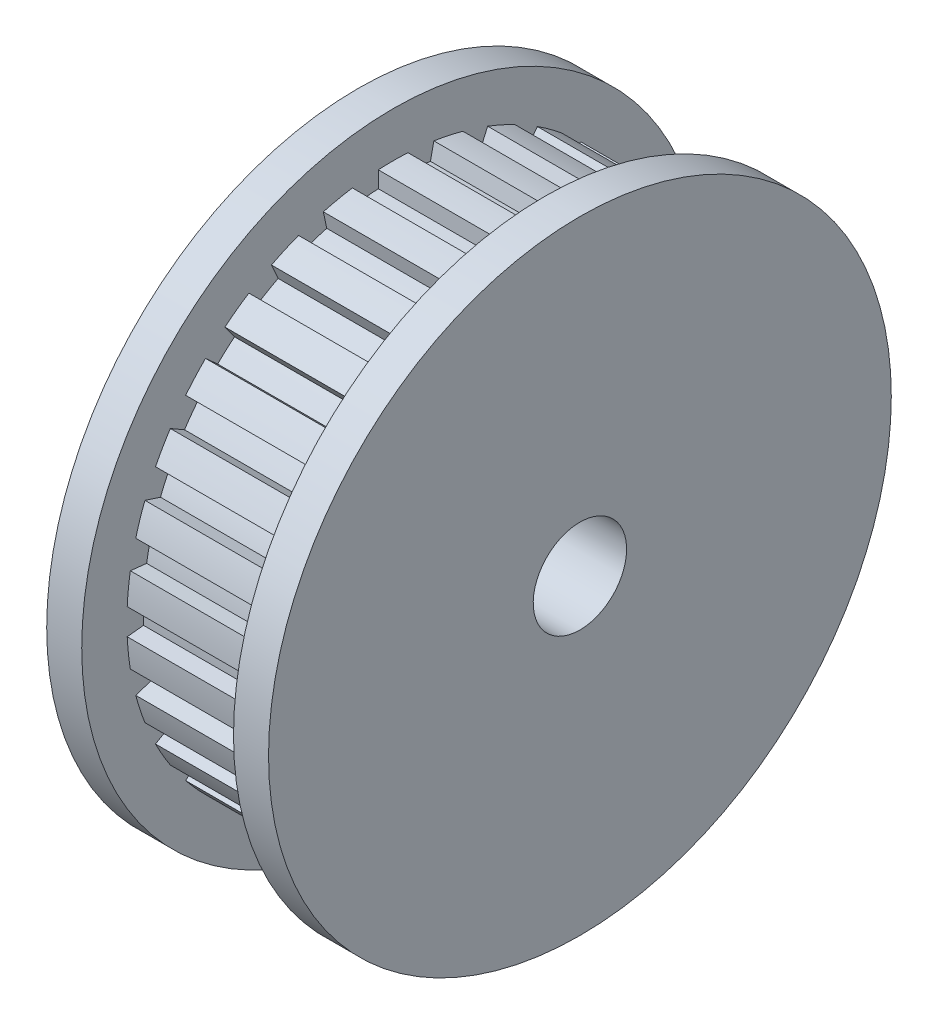
from build123d import *

# Parameters (mm, degrees)
SKETCH2_R           = 13.335
SKETCH2_R_2         = 1.999999624
BOSS_EXTRUDE1_DEPTH = 9.5
SKETCH4_W           = 6.5
SKETCH4_H           = 3.81
BOSS_EXTRUDE2_DEPTH = 6.5


with BuildPart() as part:
    # Sketch2 → Boss-Extrude1 (new body)
    with BuildSketch(Plane.ZY.offset(64.634662924)):
        with Locations((18.152779015, -99.41404144)):
            Circle(SKETCH2_R)
        with Locations((18.152779015, -99.41404144)):
            Circle(SKETCH2_R_2, mode=Mode.SUBTRACT)
    extrude(amount=-BOSS_EXTRUDE1_DEPTH)

    # Sketch4 → Cut-Revolve1 (revolve, cut)
    with BuildSketch(Plane(origin=(0, 0, 18.152779015), x_dir=(-1, 0, 0), z_dir=(0, 0, -1))):
        with Locations((59.884662924, -86.80904144)):
            Rectangle(SKETCH4_W, SKETCH4_H)
    revolve(axis=Axis((-52.493283678, -99.41404144, 18.152779015), (-1, 0, 0)), mode=Mode.SUBTRACT)

    # Sketch5 → Boss-Extrude2 (add)
    with BuildSketch(Plane(origin=(-63.134662924, 0, 0), x_dir=(0, 0, -1), z_dir=(1, 0, 0))):
        with BuildLine():
            Line((-18.787779015, -88.031243858), (-18.787779015, -88.732900349))
            ThreePointArc((-18.787779015, -88.732900349), (-18.152779015, -88.71404144), (-17.517779015, -88.732900349))
            Line((-17.517779015, -88.732900349), (-17.517779015, -88.031243858))
            ThreePointArc((-17.517779015, -88.031243858), (-18.152779015, -88.013545583), (-18.787779015, -88.031243858))
        make_face()
        with BuildLine():
            Line((-16.40728605, -88.147961372), (-16.553168638, -88.834284985))
            ThreePointArc((-16.553168638, -88.834284985), (-15.928123924, -88.947862112), (-15.310921185, -89.098332832))
            Line((-15.310921185, -89.098332832), (-15.165038597, -88.41200922))
            ThreePointArc((-15.165038597, -88.41200922), (-15.782482646, -88.26267377), (-16.40728605, -88.147961372))
        make_face()
        with BuildLine():
            Line((-14.103079504, -88.757060646), (-14.388468909, -89.398055745))
            ThreePointArc((-14.388468909, -89.398055745), (-13.800696934, -89.639105043), (-13.228266178, -89.914611282))
            Line((-13.228266178, -89.914611282), (-12.942876773, -89.273616182))
            ThreePointArc((-12.942876773, -89.273616182), (-13.515779601, -88.999170235), (-14.103079504, -88.757060646))
        make_face()
        with BuildLine():
            Line((-11.975864259, -89.831921118), (-12.388287596, -90.399573143))
            ThreePointArc((-12.388287596, -90.399573143), (-11.863476816, -90.7575596), (-11.360836013, -91.146060413))
            Line((-11.360836013, -91.146060413), (-10.948412676, -90.578408388))
            ThreePointArc((-10.948412676, -90.578408388), (-11.451735682, -90.190846547), (-11.975864259, -89.831921118))
        make_face()
        with BuildLine():
            Line((-10.118609828, -91.325566228), (-10.640042219, -91.795066061))
            ThreePointArc((-10.640042219, -91.795066061), (-10.201129383, -92.254343952), (-9.790246348, -92.738859989))
            Line((-9.790246348, -92.738859989), (-9.268813958, -92.269360156))
            ThreePointArc((-9.268813958, -92.269360156), (-9.680559512, -91.785620734), (-10.118609828, -91.325566228))
        make_face()
        with BuildLine():
            Line((-8.612487144, -93.172716518), (-9.220139489, -93.523544763))
            ThreePointArc((-9.220139489, -93.523544763), (-8.886307195, -94.06404144), (-8.585139489, -94.623397026))
            Line((-8.585139489, -94.623397026), (-7.977487144, -94.27256878))
            ThreePointArc((-7.977487144, -94.27256878), (-8.279659988, -93.713793511), (-8.612487144, -93.172716518))
        make_face()
        with BuildLine():
            Line((-7.523320994, -95.292642656), (-8.190635971, -95.509466435))
            ThreePointArc((-8.190635971, -95.509466435), (-7.976474291, -96.1075596), (-7.798184388, -96.717308211))
            Line((-7.798184388, -96.717308211), (-7.130869411, -96.500484431))
            ThreePointArc((-7.130869411, -96.500484431), (-7.310263142, -95.891094476), (-7.523320994, -95.292642656))
        make_face()
        with BuildLine():
            Line((-6.898713164, -97.592693697), (-7.596525907, -97.666036772))
            ThreePointArc((-7.596525907, -97.666036772), (-7.511394735, -98.295586883), (-7.463774759, -98.929079579))
            Line((-7.463774759, -98.929079579), (-6.765962016, -98.855736504))
            ThreePointArc((-6.765962016, -98.855736504), (-6.814736268, -98.222365127), (-6.898713164, -97.592693697))
        make_face()
        with BuildLine():
            Line((-6.765962016, -99.972346375), (-7.463774759, -99.8990033))
            ThreePointArc((-7.463774759, -99.8990033), (-7.511394735, -100.532495997), (-7.596525907, -101.162046107))
            Line((-7.596525907, -101.162046107), (-6.898713164, -101.235389182))
            ThreePointArc((-6.898713164, -101.235389182), (-6.814736268, -100.605717752), (-6.765962016, -99.972346375))
        make_face()
        with BuildLine():
            Line((-7.130869411, -102.327598448), (-7.798184388, -102.110774668))
            ThreePointArc((-7.798184388, -102.110774668), (-7.976474291, -102.720523279), (-8.190635971, -103.318616444))
            Line((-8.190635971, -103.318616444), (-7.523320994, -103.535440224))
            ThreePointArc((-7.523320994, -103.535440224), (-7.310263142, -102.936988404), (-7.130869411, -102.327598448))
        make_face()
        with BuildLine():
            Line((-7.977487144, -104.555514099), (-8.585139489, -104.204685854))
            ThreePointArc((-8.585139489, -104.204685854), (-8.886307195, -104.76404144), (-9.220139489, -105.304538116))
            Line((-9.220139489, -105.304538116), (-8.612487144, -105.655366362))
            ThreePointArc((-8.612487144, -105.655366362), (-8.279659988, -105.114289368), (-7.977487144, -104.555514099))
        make_face()
        with BuildLine():
            Line((-9.268813958, -106.558722723), (-9.790246348, -106.08922289))
            ThreePointArc((-9.790246348, -106.08922289), (-10.201129383, -106.573738928), (-10.640042219, -107.033016818))
            Line((-10.640042219, -107.033016818), (-10.118609828, -107.502516651))
            ThreePointArc((-10.118609828, -107.502516651), (-9.680559512, -107.042462145), (-9.268813958, -106.558722723))
        make_face()
        with BuildLine():
            Line((-10.948412676, -108.249674491), (-11.360836013, -107.682022466))
            ThreePointArc((-11.360836013, -107.682022466), (-11.863476816, -108.070523279), (-12.388287596, -108.428509736))
            Line((-12.388287596, -108.428509736), (-11.975864259, -108.996161761))
            ThreePointArc((-11.975864259, -108.996161761), (-11.451735682, -108.637236332), (-10.948412676, -108.249674491))
        make_face()
        with BuildLine():
            Line((-12.942876773, -109.554466697), (-13.228266178, -108.913471597))
            ThreePointArc((-13.228266178, -108.913471597), (-13.800696934, -109.188977836), (-14.388468909, -109.430027134))
            Line((-14.388468909, -109.430027134), (-14.103079504, -110.071022233))
            ThreePointArc((-14.103079504, -110.071022233), (-13.515779601, -109.828912644), (-12.942876773, -109.554466697))
        make_face()
        with BuildLine():
            Line((-15.165038597, -110.41607366), (-15.310921185, -109.729750047))
            ThreePointArc((-15.310921185, -109.729750047), (-15.928123924, -109.880220767), (-16.553168638, -109.993797894))
            Line((-16.553168638, -109.993797894), (-16.40728605, -110.680121507))
            ThreePointArc((-16.40728605, -110.680121507), (-15.782482646, -110.565409109), (-15.165038597, -110.41607366))
        make_face()
        with BuildLine():
            Line((-17.517779015, -110.796839021), (-17.517779015, -110.09518253))
            ThreePointArc((-17.517779015, -110.09518253), (-18.152779015, -110.11404144), (-18.787779015, -110.09518253))
            Line((-18.787779015, -110.09518253), (-18.787779015, -110.796839021))
            ThreePointArc((-18.787779015, -110.796839021), (-18.152779015, -110.814537296), (-17.517779015, -110.796839021))
        make_face()
        with BuildLine():
            Line((-19.89827198, -110.680121507), (-19.752389393, -109.993797894))
            ThreePointArc((-19.752389393, -109.993797894), (-20.377434107, -109.880220767), (-20.994636846, -109.729750047))
            Line((-20.994636846, -109.729750047), (-21.140519433, -110.41607366))
            ThreePointArc((-21.140519433, -110.41607366), (-20.523075385, -110.565409109), (-19.89827198, -110.680121507))
        make_face()
        with BuildLine():
            Line((-22.202478527, -110.071022233), (-21.917089121, -109.430027134))
            ThreePointArc((-21.917089121, -109.430027134), (-22.504861096, -109.188977836), (-23.077291852, -108.913471597))
            Line((-23.077291852, -108.913471597), (-23.362681258, -109.554466697))
            ThreePointArc((-23.362681258, -109.554466697), (-22.789778429, -109.828912644), (-22.202478527, -110.071022233))
        make_face()
        with BuildLine():
            Line((-24.329693772, -108.996161761), (-23.917270435, -108.428509736))
            ThreePointArc((-23.917270435, -108.428509736), (-24.442081215, -108.070523279), (-24.944722018, -107.682022466))
            Line((-24.944722018, -107.682022466), (-25.357145355, -108.249674491))
            ThreePointArc((-25.357145355, -108.249674491), (-24.853822349, -108.637236332), (-24.329693772, -108.996161761))
        make_face()
        with BuildLine():
            Line((-26.186948202, -107.502516651), (-25.665515812, -107.033016818))
            ThreePointArc((-25.665515812, -107.033016818), (-26.104428648, -106.573738928), (-26.515311682, -106.08922289))
            Line((-26.515311682, -106.08922289), (-27.036744072, -106.558722723))
            ThreePointArc((-27.036744072, -106.558722723), (-26.624998519, -107.042462145), (-26.186948202, -107.502516651))
        make_face()
        with BuildLine():
            Line((-27.693070887, -105.655366362), (-27.085418541, -105.304538116))
            ThreePointArc((-27.085418541, -105.304538116), (-27.419250836, -104.76404144), (-27.720418541, -104.204685854))
            Line((-27.720418541, -104.204685854), (-28.328070887, -104.555514099))
            ThreePointArc((-28.328070887, -104.555514099), (-28.025898043, -105.114289368), (-27.693070887, -105.655366362))
        make_face()
        with BuildLine():
            Line((-28.782237037, -103.535440224), (-28.11492206, -103.318616444))
            ThreePointArc((-28.11492206, -103.318616444), (-28.32908374, -102.720523279), (-28.507373643, -102.110774668))
            Line((-28.507373643, -102.110774668), (-29.17468862, -102.327598448))
            ThreePointArc((-29.17468862, -102.327598448), (-28.995294889, -102.936988404), (-28.782237037, -103.535440224))
        make_face()
        with BuildLine():
            Line((-29.406844866, -101.235389182), (-28.709032123, -101.162046107))
            ThreePointArc((-28.709032123, -101.162046107), (-28.794163296, -100.532495997), (-28.841783272, -99.8990033))
            Line((-28.841783272, -99.8990033), (-29.539596014, -99.972346375))
            ThreePointArc((-29.539596014, -99.972346375), (-29.490821763, -100.605717752), (-29.406844866, -101.235389182))
        make_face()
        with BuildLine():
            Line((-29.539596014, -98.855736504), (-28.841783272, -98.929079579))
            ThreePointArc((-28.841783272, -98.929079579), (-28.794163296, -98.295586883), (-28.709032123, -97.666036772))
            Line((-28.709032123, -97.666036772), (-29.406844866, -97.592693697))
            ThreePointArc((-29.406844866, -97.592693697), (-29.490821763, -98.222365127), (-29.539596014, -98.855736504))
        make_face()
        with BuildLine():
            Line((-29.17468862, -96.500484431), (-28.507373643, -96.717308211))
            ThreePointArc((-28.507373643, -96.717308211), (-28.32908374, -96.1075596), (-28.11492206, -95.509466435))
            Line((-28.11492206, -95.509466435), (-28.782237037, -95.292642656))
            ThreePointArc((-28.782237037, -95.292642656), (-28.995294889, -95.891094476), (-29.17468862, -96.500484431))
        make_face()
        with BuildLine():
            Line((-28.328070887, -94.27256878), (-27.720418541, -94.623397026))
            ThreePointArc((-27.720418541, -94.623397026), (-27.419250836, -94.06404144), (-27.085418541, -93.523544763))
            Line((-27.085418541, -93.523544763), (-27.693070887, -93.172716518))
            ThreePointArc((-27.693070887, -93.172716518), (-28.025898043, -93.713793511), (-28.328070887, -94.27256878))
        make_face()
        with BuildLine():
            Line((-27.036744072, -92.269360156), (-26.515311682, -92.738859989))
            ThreePointArc((-26.515311682, -92.738859989), (-26.104428648, -92.254343952), (-25.665515812, -91.795066061))
            Line((-25.665515812, -91.795066061), (-26.186948202, -91.325566228))
            ThreePointArc((-26.186948202, -91.325566228), (-26.624998519, -91.785620734), (-27.036744072, -92.269360156))
        make_face()
        with BuildLine():
            Line((-25.357145355, -90.578408388), (-24.944722018, -91.146060413))
            ThreePointArc((-24.944722018, -91.146060413), (-24.442081215, -90.7575596), (-23.917270435, -90.399573143))
            Line((-23.917270435, -90.399573143), (-24.329693772, -89.831921118))
            ThreePointArc((-24.329693772, -89.831921118), (-24.853822349, -90.190846547), (-25.357145355, -90.578408388))
        make_face()
        with BuildLine():
            Line((-23.362681258, -89.273616182), (-23.077291852, -89.914611282))
            ThreePointArc((-23.077291852, -89.914611282), (-22.504861096, -89.639105043), (-21.917089121, -89.398055745))
            Line((-21.917089121, -89.398055745), (-22.202478527, -88.757060646))
            ThreePointArc((-22.202478527, -88.757060646), (-22.789778429, -88.999170235), (-23.362681258, -89.273616182))
        make_face()
        with BuildLine():
            Line((-21.140519433, -88.41200922), (-20.994636846, -89.098332832))
            ThreePointArc((-20.994636846, -89.098332832), (-20.377434107, -88.947862112), (-19.752389393, -88.834284985))
            Line((-19.752389393, -88.834284985), (-19.89827198, -88.147961372))
            ThreePointArc((-19.89827198, -88.147961372), (-20.523075385, -88.26267377), (-21.140519433, -88.41200922))
        make_face()
    extrude(amount=BOSS_EXTRUDE2_DEPTH)


solid = part.part
